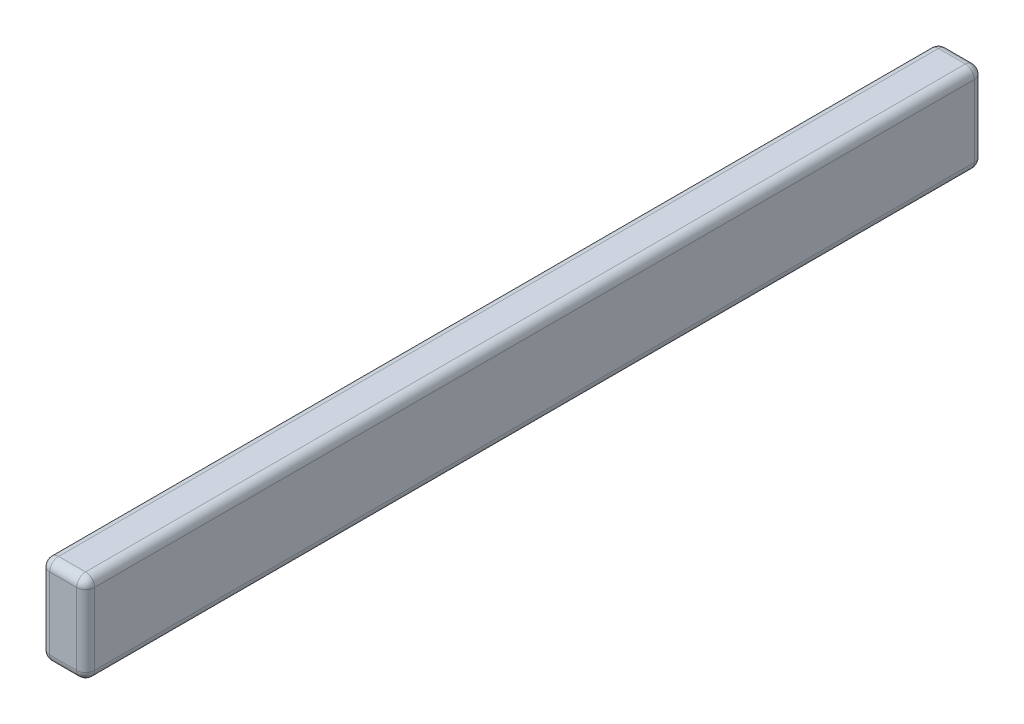
from build123d import *

# Parameters (mm, degrees)
ESQUISSE1_W        = 50
ESQUISSE1_H        = 100
BOSS_EXTRU_1_DEPTH = 1000
CONG_1_R           = 10
CONG_2_R           = 10


with BuildPart() as part:
    # Esquisse1 → Boss.-Extru.1 (new body)
    with BuildSketch(Plane.XY):
        with Locations((-3.29344948, -25.030257009)):
            Rectangle(ESQUISSE1_W, ESQUISSE1_H)
    extrude(amount=BOSS_EXTRU_1_DEPTH)

    # Congé1
    cong_1_edges = [part.edges().sort_by_distance(p)[0] for p in [
        (-28.29344948, 24.969742991, 500),
        (21.70655052, 24.969742991, 500),
        (21.70655052, -75.030257009, 500),
        (-28.29344948, -75.030257009, 500),
    ]]
    fillet(cong_1_edges, radius=CONG_1_R)

    # Congé2
    cong_2_edges = [part.edges().sort_by_distance(p)[0] for p in [
        (-3.29344948, 24.969742991, 0),
        (-3.29344948, 24.969742991, 1000),
        (-28.29344948, -25.030257009, 0),
        (21.70655052, -25.030257009, 0),
        (-3.29344948, -75.030257009, 0),
        (-25.364517292, -72.101324821, 0),
        (18.777618331, -72.101324821, 0),
        (-25.364517292, 22.040810803, 0),
        (18.777618331, 22.040810803, 0),
        (21.70655052, -25.030257009, 1000),
        (-28.29344948, -25.030257009, 1000),
        (-3.29344948, -75.030257009, 1000),
        (-25.364517292, -72.101324821, 1000),
        (18.777618331, -72.101324821, 1000),
        (-25.364517292, 22.040810803, 1000),
        (18.777618331, 22.040810803, 1000),
    ]]
    fillet(cong_2_edges, radius=CONG_2_R)


solid = part.part
